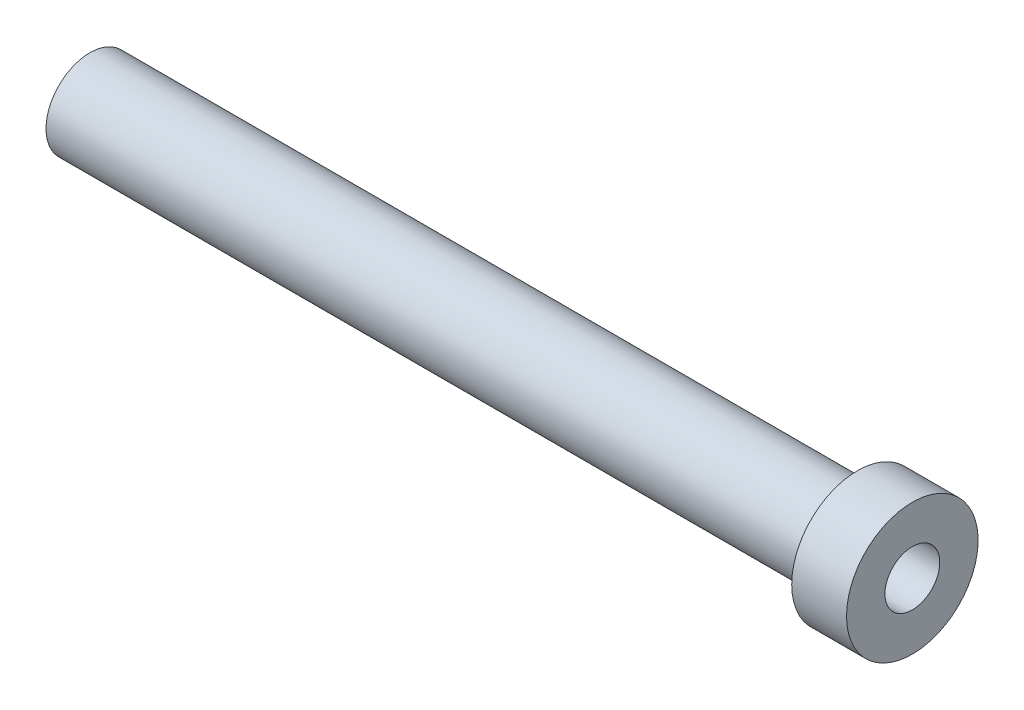
from build123d import *

# Parameters (mm, degrees)
SKETCH_2_R          = 2.5
CUT_EXTRUDE_1_DEPTH = 76


with BuildPart() as part:
    # Эскиз1 → Повернуть1 (revolve)
    with BuildSketch(Plane.XY, mode=Mode.PRIVATE) as revolve_1_sk:
        Polygon((6.661184211, 0), (6.661184211, 4), (76.661184211, 4), (76.661184211, 6), (81.661184211, 6), (81.661184211, 0), align=None)
    revolve(revolve_1_sk.sketch.rotate(Axis((0, 0, 0), (1, 0, 0)), 90), axis=Axis((0, 0, 0), (1, 0, 0)))  # turned: the seam where the file's is

    # Эскиз2 → Вырез-Вытянуть1 (cut, through all)
    with BuildSketch(Plane(origin=(81.661184211, 0, 0), x_dir=(0, 0, -1), z_dir=(1, 0, 0))):
        Circle(SKETCH_2_R)
    extrude(amount=-CUT_EXTRUDE_1_DEPTH, mode=Mode.SUBTRACT)


solid = part.part
